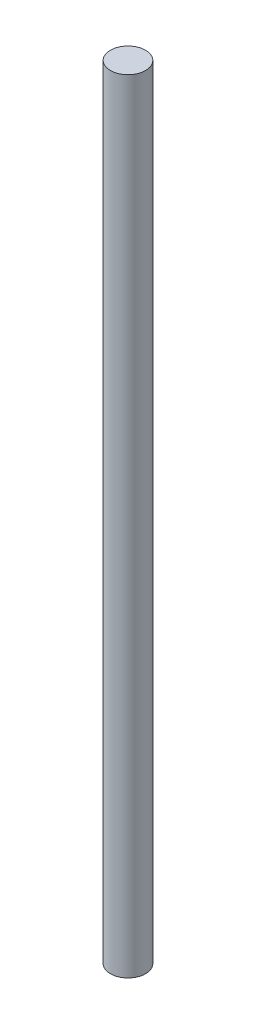
from build123d import *

# Parameters (mm, degrees)
SKETCH1_R           = 3.19
BOSS_EXTRUDE1_DEPTH = 142


with BuildPart() as part:
    # Sketch1 → Boss-Extrude1 (new body)
    with BuildSketch(Plane(origin=(0, 0, 0), x_dir=(1, 0, 0), z_dir=(0, 1, 0))):
        Circle(SKETCH1_R)
    extrude(amount=BOSS_EXTRUDE1_DEPTH)


solid = part.part
